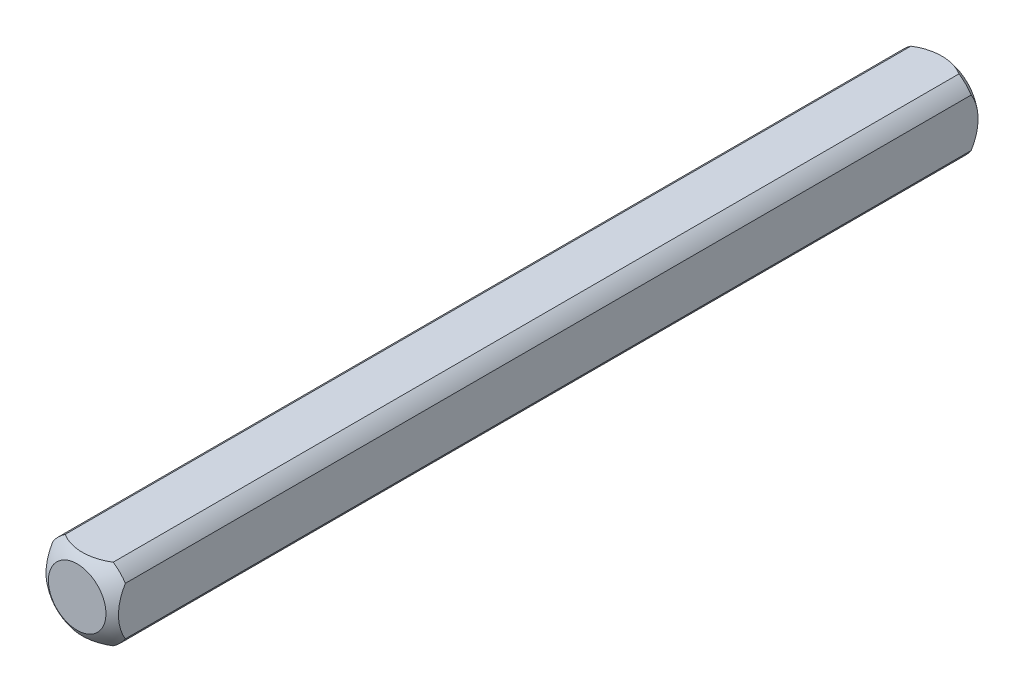
from build123d import *

# Parameters (mm, degrees)
SKETCH1_W           = 6.35
SKETCH1_H           = 6.35
BOSS_EXTRUDE1_DEPTH = 38.1
SKETCH2_OUTSIDE_W   = 16.178
SKETCH2_OUTSIDE_H   = 16.178
SKETCH2_OUTSIDE_R   = 3.81
CUT_EXTRUDE1_DEPTH  = 39.1


with BuildPart() as part:
    # Sketch1 → Boss-Extrude1 (new body)
    with BuildSketch(Plane.XY):
        Rectangle(SKETCH1_W, SKETCH1_H)
    extrude(amount=BOSS_EXTRUDE1_DEPTH)

    # Sketch2 outside → Cut-Extrude1 (cut, through all)
    with BuildSketch(Plane(origin=(0, 0, 0), x_dir=(-1, 0, 0), z_dir=(0, 0, -1))):
        Rectangle(SKETCH2_OUTSIDE_W, SKETCH2_OUTSIDE_H)
        Circle(SKETCH2_OUTSIDE_R, mode=Mode.SUBTRACT)
    extrude(amount=-CUT_EXTRUDE1_DEPTH, mode=Mode.SUBTRACT)

    # Sketch3 → Cut-Revolve1 (revolve, cut)
    with BuildSketch(Plane(origin=(0, 0, 0), x_dir=(1, 0, 0), z_dir=(0, 1, 0))):
        with BuildLine():
            Line((-5.053685963, -3.893335876), (-5.053685963, 5.740530545))
            Line((-5.053685963, 5.740530545), (0, 5.740530545))
            Line((0, 5.740530545), (0, 0.670274551))
            ThreePointArc((0, 0.670274551), (-3.404639553, -0.639469554), (-5.053685963, -3.893335876))
        make_face()
    revolve(axis=Axis((0, 0, 38.1), (0, 0, -1)), mode=Mode.SUBTRACT)

    # Mirror1: part across plane


with BuildPart() as part_1:
    add(part.part)
    add(part.part.mirror(Plane(origin=(0, 0, 38.1), x_dir=(1, 0, 0), z_dir=(0, 0, -1))))


solid = part_1.part
